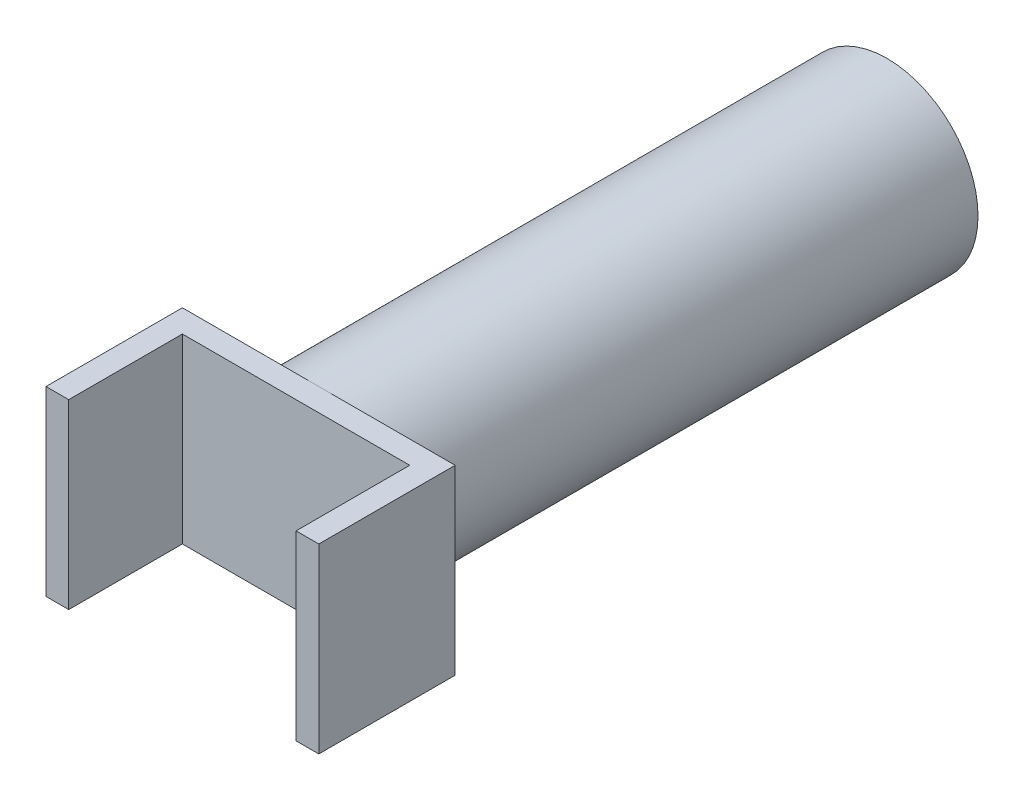
from build123d import *

# Parameters (mm, degrees)
SZKIC1_R                    = 40
DODANIE_WYCI_GNI_CIE1_DEPTH = 250
SZKIC2_W                    = 120
SZKIC2_H                    = 80
DODANIE_WYCI_GNI_CIE2_DEPTH = 10
SZKIC3_W                    = 10
SZKIC3_H                    = 80
DODANIE_WYCI_GNI_CIE3_DEPTH = 50


with BuildPart() as part:
    # Szkic1 → Dodanie-wyciągnięcie1 (new body)
    with BuildSketch(Plane.XY):
        Circle(SZKIC1_R)
    extrude(amount=DODANIE_WYCI_GNI_CIE1_DEPTH)

    # Szkic2 → Dodanie-wyciągnięcie2 (add)
    with BuildSketch(Plane.XY.offset(250)):
        Rectangle(SZKIC2_W, SZKIC2_H)
    extrude(amount=DODANIE_WYCI_GNI_CIE2_DEPTH)

    # Szkic3 → Dodanie-wyciągnięcie3 (add)
    with BuildSketch(Plane.XY.offset(260)):
        with Locations((-55, 0)):
            Rectangle(SZKIC3_W, SZKIC3_H)
        with Locations((55, 0)):
            Rectangle(SZKIC3_W, SZKIC3_H)
    extrude(amount=DODANIE_WYCI_GNI_CIE3_DEPTH)


solid = part.part
